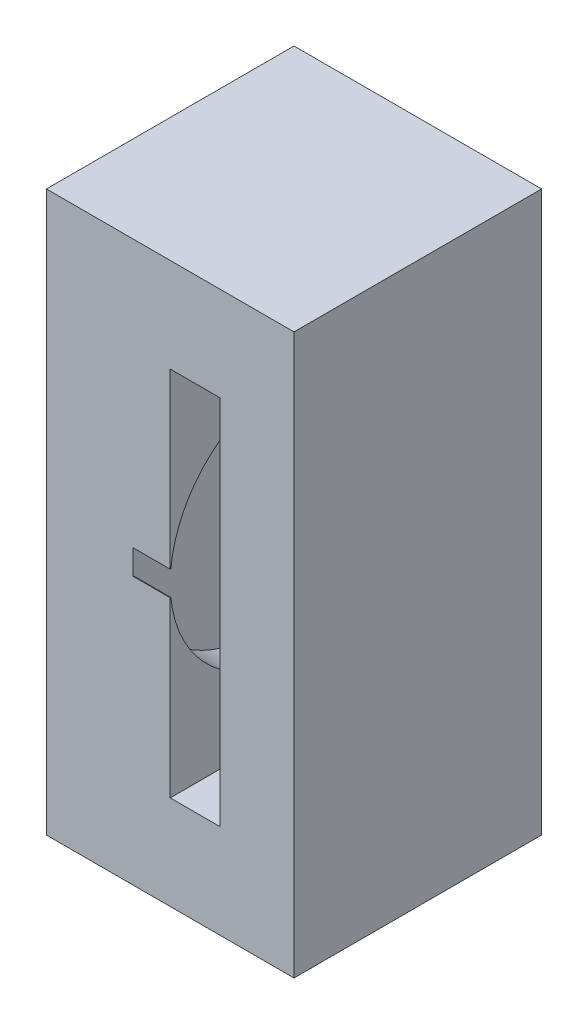
from build123d import *

# Parameters (mm, degrees)
SKETCH1_W           = 100
SKETCH1_H           = 100
BOSS_EXTRUDE1_DEPTH = 226
SKETCH5_W           = 35.1
SKETCH5_H           = 150
CUT_EXTRUDE1_DEPTH  = 101
BOSS_EXTRUDE2_DEPTH = 15
BOSS_EXTRUDE4_DEPTH = 19


with BuildPart() as part:
    # Sketch1 → Boss-Extrude1 (new body)
    with BuildSketch(Plane(origin=(0, 0, 0), x_dir=(1, 0, 0), z_dir=(0, 1, 0))):
        Rectangle(SKETCH1_W, SKETCH1_H)
    extrude(amount=BOSS_EXTRUDE1_DEPTH)

    # Sketch5 → Cut-Extrude1 (cut, through all)
    with BuildSketch(Plane(origin=(0, 0, -50), x_dir=(-1, 0, 0), z_dir=(0, 0, -1))):
        with Locations((-2.55, 113)):
            Rectangle(SKETCH5_W, SKETCH5_H)
    extrude(amount=-CUT_EXTRUDE1_DEPTH, mode=Mode.SUBTRACT)

    # Sketch6 → Boss-Extrude2 (add)
    with BuildSketch(Plane(origin=(-15, 0, 0), x_dir=(0, 0, -1), z_dir=(1, 0, 0))):
        with BuildLine():
            ThreePointArc((-2, 118.921359641), (-6.25, 113), (-2, 107.078640359))
            Line((-2, 107.078640359), (-2, 118.921359641))
        make_face()
        with BuildLine():
            Line((2, 118.921359641), (2, 107.078640359))
            ThreePointArc((2, 107.078640359), (6.25, 113), (2, 118.921359641))
        make_face()
        with BuildLine():
            Line((-50, 118), (-49.749371855, 118))
            ThreePointArc((-49.749371855, 118), (0, 163), (49.749371855, 118))
            Line((49.749371855, 118), (50, 118))
            Line((50, 118), (50, 188))
            Line((50, 188), (-50, 188))
            Line((-50, 188), (-50, 118))
        make_face()
        with BuildLine():
            ThreePointArc((49.749371855, 108), (0, 63), (-49.749371855, 108))
            Line((-49.749371855, 108), (-50, 108))
            Line((-50, 108), (-50, 38))
            Line((-50, 38), (50, 38))
            Line((50, 38), (50, 108))
            Line((50, 108), (49.749371855, 108))
        make_face()
    extrude(amount=BOSS_EXTRUDE2_DEPTH)

    # Sketch10 → Boss-Extrude4 (add)
    with BuildSketch(Plane.ZY.offset(-20.1)):
        with BuildLine():
            Line((-2, 119.184658438), (-2, 106.815341562))
            ThreePointArc((-2, 106.815341562), (-6.5, 113), (-2, 119.184658438))
        make_face()
        with BuildLine():
            Line((2, 119.184658438), (2, 106.815341562))
            ThreePointArc((2, 106.815341562), (6.5, 113), (2, 119.184658438))
        make_face()
    extrude(amount=BOSS_EXTRUDE4_DEPTH)


solid = part.part
